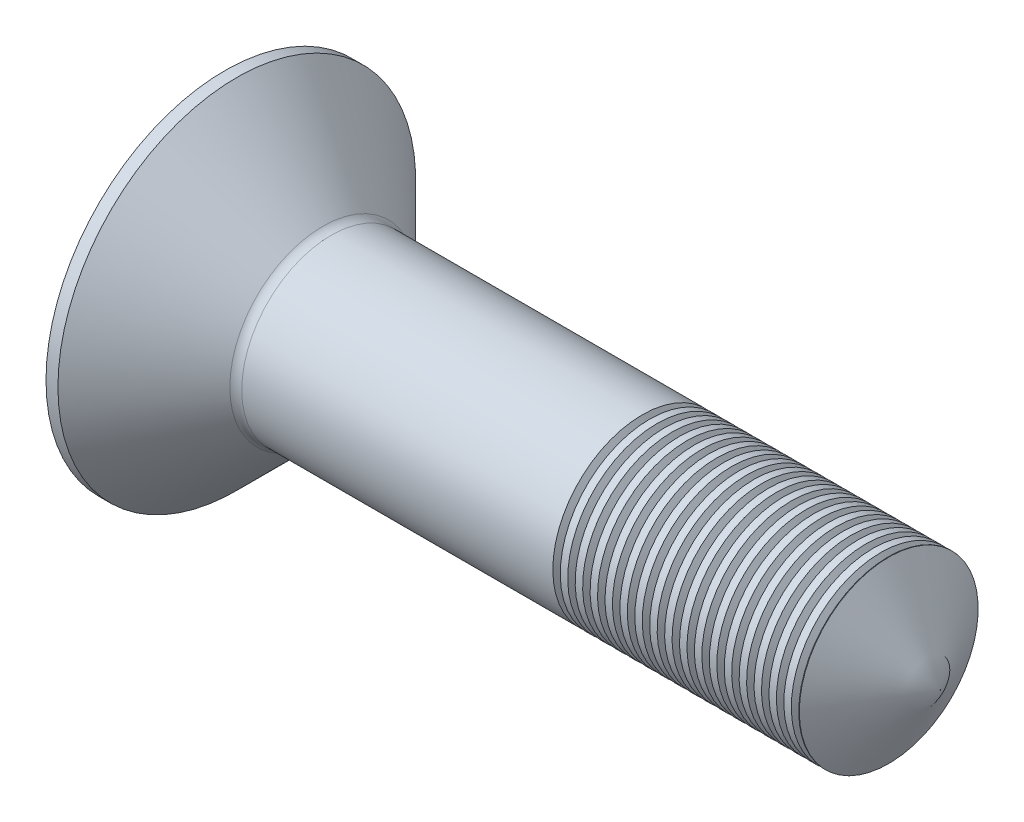
from build123d import *

# Parameters (mm, degrees)
FILLET2_R        = 0.2
LPATTERN10_COUNT = 20
LPATTERN10_PITCH = 0.25


with BuildPart() as part:
    # Sketch1 → Base (revolve)
    with BuildSketch(Plane(origin=(0, 0, 0), x_dir=(1, 0, 0), z_dir=(0, 1, 0))):
        Polygon((1.7, 1.5), (12, 1.5), (12, 0), (0, 0), (0, 3), (0.2, 3), align=None)
    revolve(axis=Axis((-6.506452013, 0, 0), (1, 0, 0)))

    # Sketch3 → Cut-Revolve1 (revolve, cut)
    with BuildSketch(Plane.XY):
        Polygon((12.15755877, 0), (12.15755877, 20), (0.452994616, 20), (12, 0), align=None)
    revolve(axis=Axis((4.883468835, 0, 0), (1, 0, 0)), mode=Mode.SUBTRACT)

    # Fillet2
    fillet2_edges = [part.edges().sort_by_distance(p)[0] for p in [
        (1.7, 0, 1.5),
    ]]
    fillet(fillet2_edges, radius=FILLET2_R)

    # Sketch2 → Cut-Loft1 section 0
    with BuildSketch(Plane(origin=(0, -0.680816871, 0.306758275), x_dir=(0, 0, 1), z_dir=(-1, 0, 0)), mode=Mode.PRIVATE) as cut_loft1_s0:
        Polygon((-0.686758275, 1.060816871), (-2.206758275, 1.060816871), (-2.206758275, 0.300816871), (-0.686758275, 0.300816871), (-0.686758275, -1.219183129), (0.073241725, -1.219183129), (0.073241725, 0.300816871), (1.593241725, 0.300816871), (1.593241725, 1.060816871), (0.073241725, 1.060816871), (0.073241725, 2.580816871), (-0.686758275, 2.580816871), align=None)
    loft([cut_loft1_s0.sketch, Vertex(1.95, 0, 0)], mode=Mode.SUBTRACT)

    # Sketch5 → Cut-Revolve10 (revolve, cut)
    with BuildSketch(Plane.XY):
        Polygon((7, 1.7), (7.125, 1.7), (7.125, 1.5), (7.0625, 1.391746825), (7, 1.5), align=None)
    cut_revolve10 = revolve(axis=Axis((10.774329131, 0, 0), (-1, 0, 0)), mode=Mode.SUBTRACT)

    # LPattern10: Cut-Revolve10 ×20
    with Locations(*[(i * LPATTERN10_PITCH, 0, 0) for i in range(1, LPATTERN10_COUNT)]):
        add(cut_revolve10, mode=Mode.SUBTRACT)


solid = part.part
